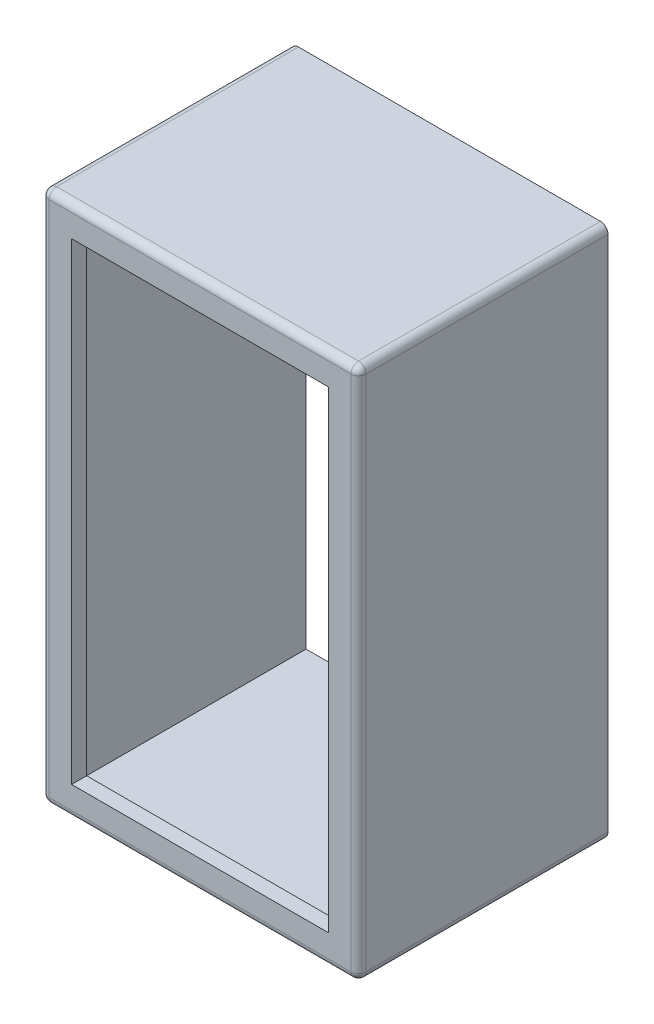
from build123d import *

# Parameters (mm, degrees)
SKETCH1_W           = 10.7315
SKETCH1_H           = 18.034
BOSS_EXTRUDE1_DEPTH = 7.9375
SHELL1_T            = -0.508
SKETCH2_W           = 10.7315
SKETCH2_H           = 18.034
SKETCH2_W_2         = 8.6995
SKETCH2_H_2         = 16.002
EXTRUDE_THIN1_DEPTH = 0.508
FILLET2_R           = 0.254


with BuildPart() as part:
    # Sketch1 → Boss-Extrude1 (new body)
    with BuildSketch(Plane.XY):
        with Locations((14.669644351, 41.878696913)):
            Rectangle(SKETCH1_W, SKETCH1_H)
    extrude(amount=BOSS_EXTRUDE1_DEPTH)

    # Shell1
    shell1_openings = [part.faces().sort_by_distance(p)[0] for p in [
        (14.669644351, 41.878696913, 7.9375),
        (14.669644351, 41.878696913, 0),
    ]]
    offset(amount=SHELL1_T, openings=shell1_openings, kind=Kind.INTERSECTION)

    # Sketch2 → Extrude-Thin1 (add)
    with BuildSketch(Plane.XY.offset(7.9375)):
        with Locations((14.669644351, 41.878696913)):
            Rectangle(SKETCH2_W, SKETCH2_H)
        with Locations((14.669644351, 41.878696913)):
            Rectangle(SKETCH2_W_2, SKETCH2_H_2, mode=Mode.SUBTRACT)
    extrude(amount=EXTRUDE_THIN1_DEPTH)

    # Fillet2
    fillet2_edges = [part.edges().sort_by_distance(p)[0] for p in [
        (14.669644351, 32.861696913, 8.4455),
        (20.035394351, 41.878696913, 8.4455),
        (14.669644351, 50.895696913, 8.4455),
        (9.303894351, 41.878696913, 8.4455),
        (9.303894351, 50.895696913, 4.22275),
        (20.035394351, 50.895696913, 4.22275),
        (20.035394351, 32.861696913, 4.22275),
        (9.303894351, 32.861696913, 4.22275),
    ]]
    fillet(fillet2_edges, radius=FILLET2_R)


solid = part.part
